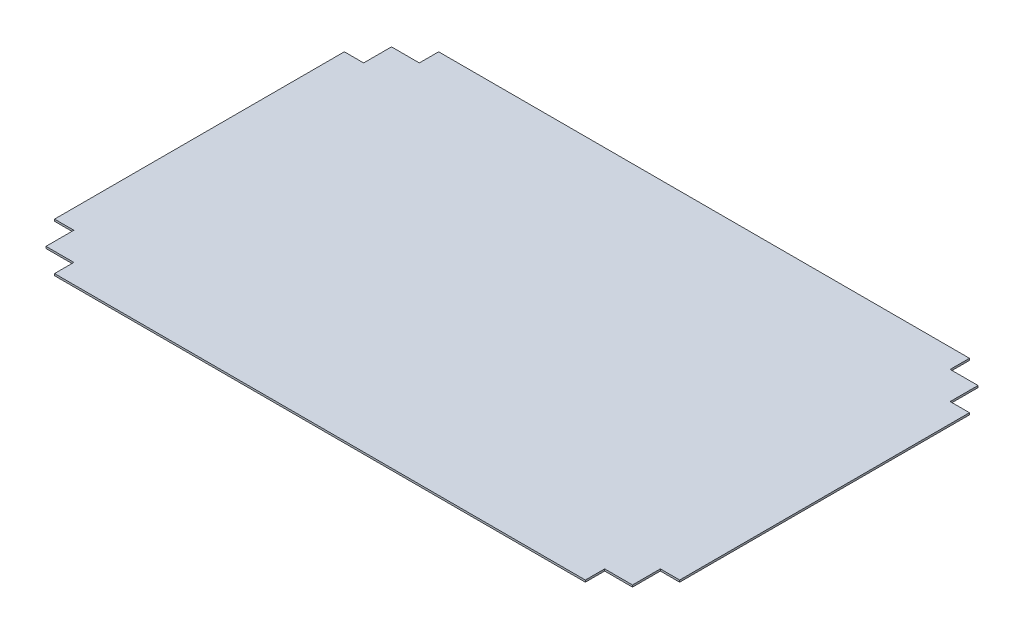
from build123d import *

# Parameters (mm, degrees)
BOSS_EXTRUDE1_DEPTH = 2


with BuildPart() as part:
    # Sketch1 → Boss-Extrude1 (new body)
    with BuildSketch(Plane(origin=(0, 0, 0), x_dir=(1, 0, 0), z_dir=(0, 1, 0))):
        Polygon((-325.499342603, 150.901111002), (-307.000657397, 150.901111002), (-305.400657397, 150.901111002), (-305.400657397, 179.901111002), (-276.400657397, 179.901111002), (-276.400657397, 199.998908398), (276.400657397, 199.998908398), (276.400657397, 179.901111002), (305.400657397, 179.901111002), (305.400657397, 150.901111002), (325.499342603, 150.901111002), (325.499342603, -150.901091602), (305.400657397, -150.901091602), (305.400657397, -179.901091602), (276.400657397, -179.901091602), (276.400657397, -199.998908398), (-276.400657397, -199.998908398), (-276.400657397, -179.901091602), (-305.400657397, -179.901091602), (-305.400657397, -150.901091602), (-325.499342603, -150.901091602), align=None)
    extrude(amount=BOSS_EXTRUDE1_DEPTH)


solid = part.part
